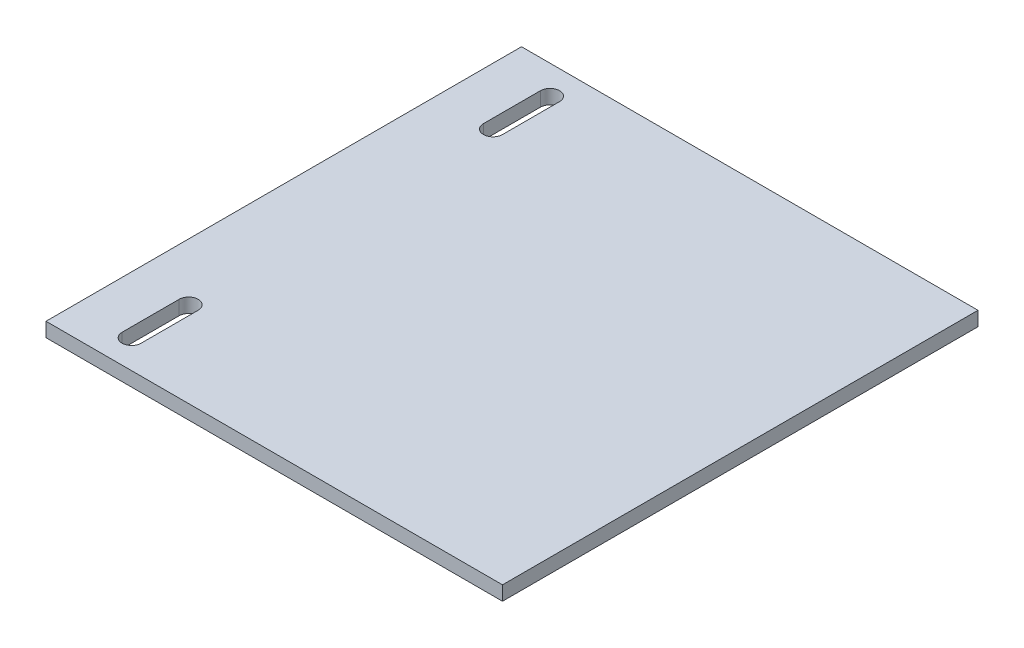
from build123d import *

# Parameters (mm, degrees)
SKETCH1_W           = 152.4
SKETCH1_H           = 158.75
BOSS_EXTRUDE1_DEPTH = 4.7625
CUT_EXTRUDE1_DEPTH  = 5.7625


with BuildPart() as part:
    # Sketch1 → Boss-Extrude1 (new body)
    with BuildSketch(Plane(origin=(0, 0, 0), x_dir=(1, 0, 0), z_dir=(0, 1, 0))):
        Rectangle(SKETCH1_W, SKETCH1_H)
    extrude(amount=BOSS_EXTRUDE1_DEPTH)

    # Sketch2 → Cut-Extrude1 (cut, through all)
    with BuildSketch(Plane(origin=(0, 4.7625, 0), x_dir=(1, 0, 0), z_dir=(0, 1, 0))):
        with BuildLine():
            Line((-53.975, 50.8), (-53.975, 69.85))
            ThreePointArc((-53.975, 69.85), (-57.15, 73.025), (-60.325, 69.85))
            Line((-60.325, 69.85), (-60.325, 50.8))
            ThreePointArc((-60.325, 50.8), (-57.15, 47.625), (-53.975, 50.8))
        make_face()
        with BuildLine():
            Line((-60.325, -50.8), (-60.325, -69.85))
            ThreePointArc((-60.325, -69.85), (-57.15, -73.025), (-53.975, -69.85))
            Line((-53.975, -69.85), (-53.975, -50.8))
            ThreePointArc((-53.975, -50.8), (-57.15, -47.625), (-60.325, -50.8))
        make_face()
    extrude(amount=-CUT_EXTRUDE1_DEPTH, mode=Mode.SUBTRACT)


solid = part.part
